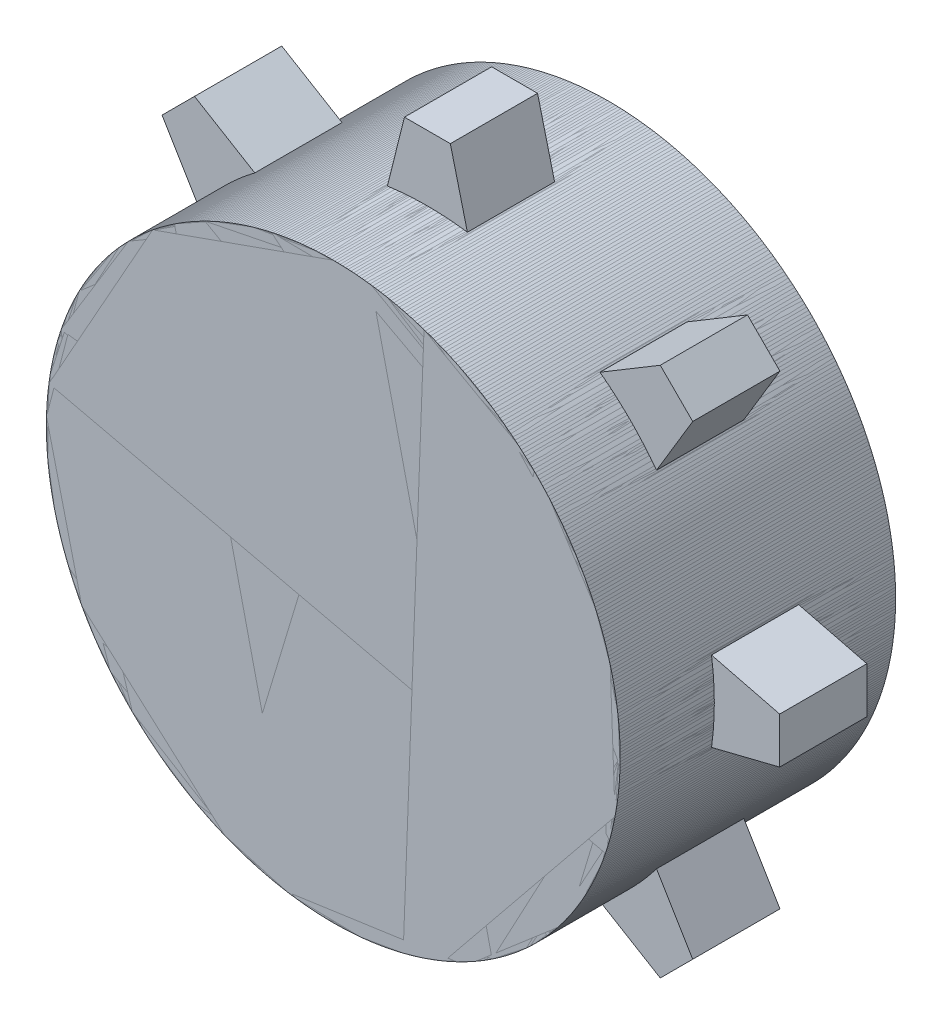
from build123d import *

# Parameters (mm, degrees)
SKETCH1_R           = 31.25
BOSS_EXTRUDE1_DEPTH = 15
BOSS_EXTRUDE2_DEPTH = 4.75
CIRPATTERN1_COUNT   = 8


with BuildPart() as part:
    # Sketch1 → Boss-Extrude1 (new body, symmetric)
    with BuildSketch(Plane.XY):
        Circle(SKETCH1_R)
    extrude(amount=BOSS_EXTRUDE1_DEPTH, both=True)

    # Sketch2 → Boss-Extrude2 (add, symmetric)
    with BuildSketch(Plane.XY):
        Polygon((-28.372098708, -5), (-28.372098708, 5), (-38.372098708, 2.5), (-38.372098708, -2.5), align=None)
    extrude(amount=BOSS_EXTRUDE2_DEPTH, both=True)


with BuildPart() as cirpattern1_1:
    # CirPattern1: pattern copy
    add(part.part.rotate(Axis((0, 0, 0), (0, 0, 1)), 1 * 360 / CIRPATTERN1_COUNT))


with BuildPart() as cirpattern1_2:
    # CirPattern1: pattern copy
    add(part.part.rotate(Axis((0, 0, 0), (0, 0, 1)), 2 * 360 / CIRPATTERN1_COUNT))


with BuildPart() as cirpattern1_3:
    # CirPattern1: pattern copy
    add(part.part.rotate(Axis((0, 0, 0), (0, 0, 1)), 3 * 360 / CIRPATTERN1_COUNT))


with BuildPart() as cirpattern1_4:
    # CirPattern1: pattern copy
    add(part.part.rotate(Axis((0, 0, 0), (0, 0, 1)), 4 * 360 / CIRPATTERN1_COUNT))


with BuildPart() as cirpattern1_5:
    # CirPattern1: pattern copy
    add(part.part.rotate(Axis((0, 0, 0), (0, 0, 1)), 5 * 360 / CIRPATTERN1_COUNT))


with BuildPart() as cirpattern1_6:
    # CirPattern1: pattern copy
    add(part.part.rotate(Axis((0, 0, 0), (0, 0, 1)), 6 * 360 / CIRPATTERN1_COUNT))


with BuildPart() as cirpattern1_7:
    # CirPattern1: pattern copy
    add(part.part.rotate(Axis((0, 0, 0), (0, 0, 1)), 7 * 360 / CIRPATTERN1_COUNT))


solid = Compound([part.part, cirpattern1_1.part, cirpattern1_2.part, cirpattern1_3.part, cirpattern1_4.part, cirpattern1_5.part, cirpattern1_6.part, cirpattern1_7.part])
